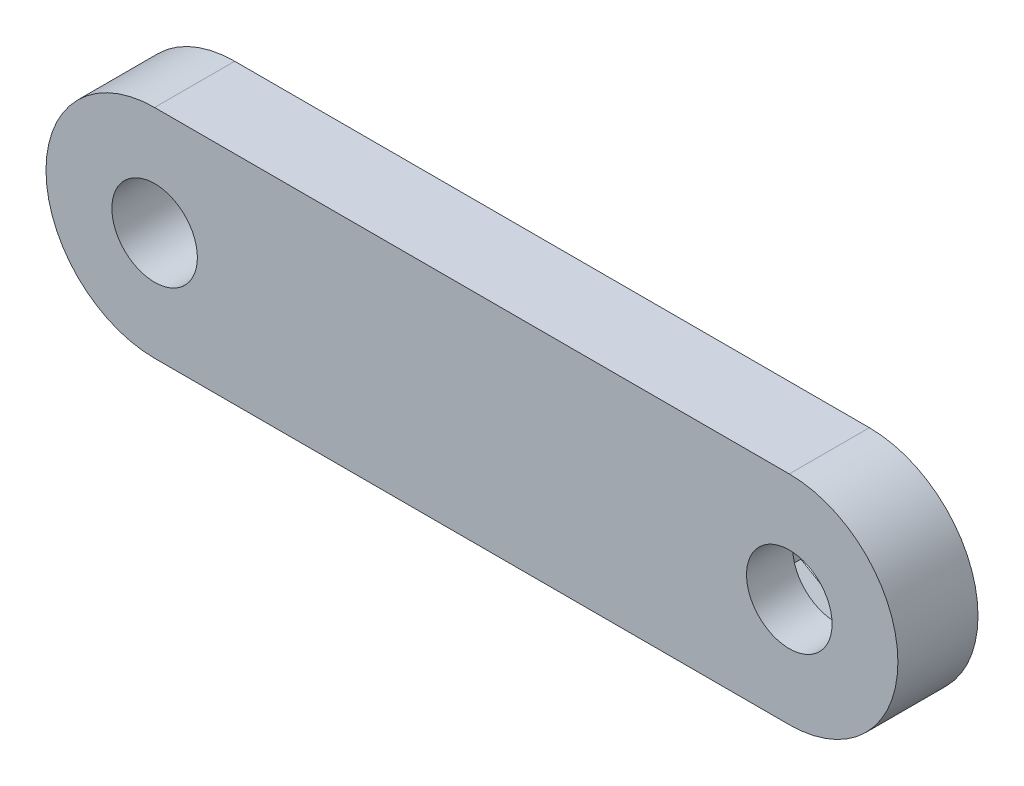
from build123d import *

# Parameters (mm, degrees)
SKETCH1_R           = 3.15
BOSS_EXTRUDE1_DEPTH = 5.9
CUT_EXTRUDE2_DEPTH  = 2.5


with BuildPart() as part:
    # Sketch1 → Boss-Extrude1 (new body)
    with BuildSketch(Plane.XY):
        with BuildLine():
            Line((23.375, -8), (-23.375, -8))
            ThreePointArc((-23.375, -8), (-31.375, 0), (-23.375, 8))
            Line((-23.375, 8), (23.375, 8))
            ThreePointArc((23.375, 8), (31.375, 0), (23.375, -8))
        make_face()
        with Locations((23.375, 0)):
            Circle(SKETCH1_R, mode=Mode.SUBTRACT)
        with Locations((-23.375, 0)):
            Circle(SKETCH1_R, mode=Mode.SUBTRACT)
    extrude(amount=BOSS_EXTRUDE1_DEPTH)

    # Sketch2 → Cut-Extrude2 (cut)
    with BuildSketch(Plane.XY):
        Polygon((23.375, 5.831237719), (18.325, 2.915618859), (18.325, -2.915618859), (23.375, -5.831237719), (28.425, -2.915618859), (28.425, 2.915618859), align=None)
    extrude(amount=CUT_EXTRUDE2_DEPTH, mode=Mode.SUBTRACT)


solid = part.part
